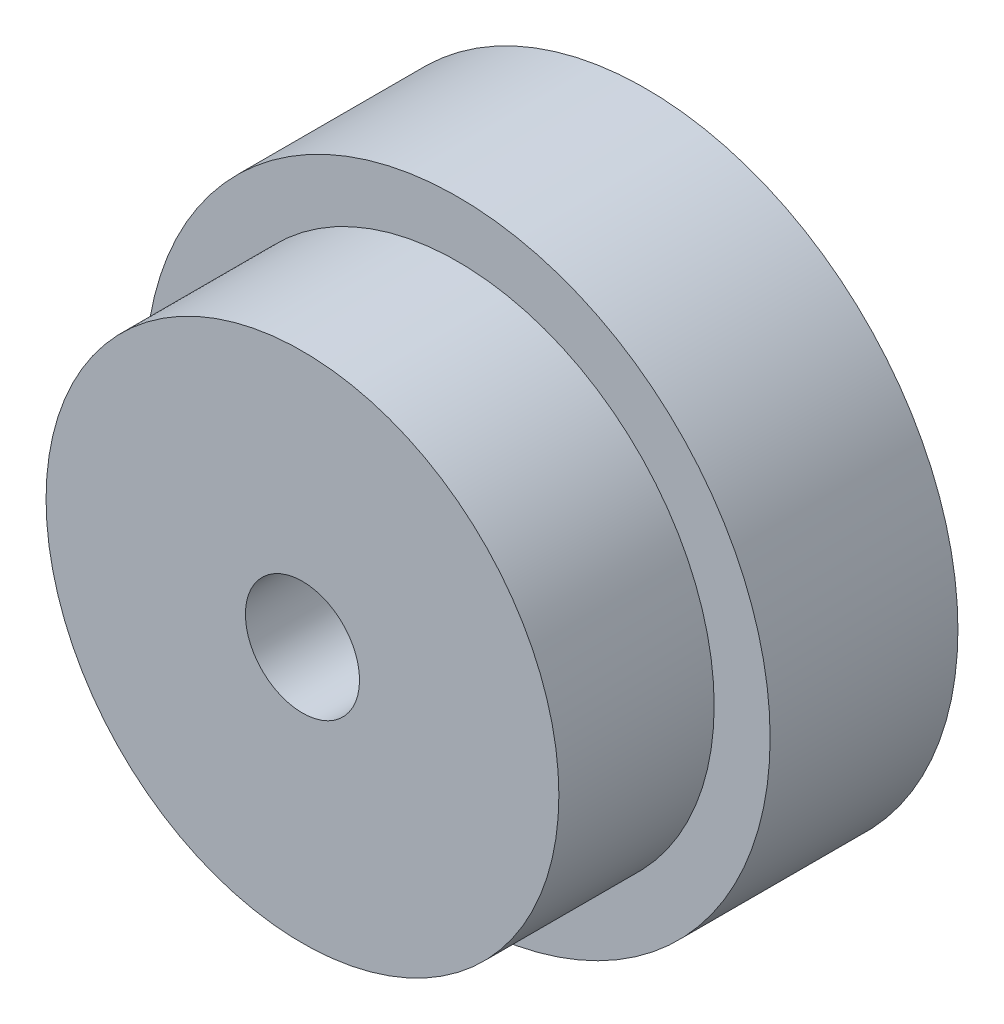
from build123d import *

# Parameters (mm, degrees)
SKETCH1_R           = 10.9855
BOSS_EXTRUDE1_DEPTH = 6.604
SKETCH2_R           = 9.017
BOSS_EXTRUDE2_DEPTH = 5.461
SKETCH3_R           = 2.0066
CUT_EXTRUDE1_DEPTH  = 13.065


with BuildPart() as part:
    # Sketch1 → Boss-Extrude1 (new body)
    with BuildSketch(Plane.XY):
        Circle(SKETCH1_R)
    extrude(amount=BOSS_EXTRUDE1_DEPTH)

    # Sketch2 → Boss-Extrude2 (add)
    with BuildSketch(Plane.XY.offset(6.604)):
        Circle(SKETCH2_R)
    extrude(amount=BOSS_EXTRUDE2_DEPTH)

    # Sketch3 → Cut-Extrude1 (cut, through all)
    with BuildSketch(Plane.XY.offset(12.065)):
        Circle(SKETCH3_R)
    extrude(amount=-CUT_EXTRUDE1_DEPTH, mode=Mode.SUBTRACT)


solid = part.part
